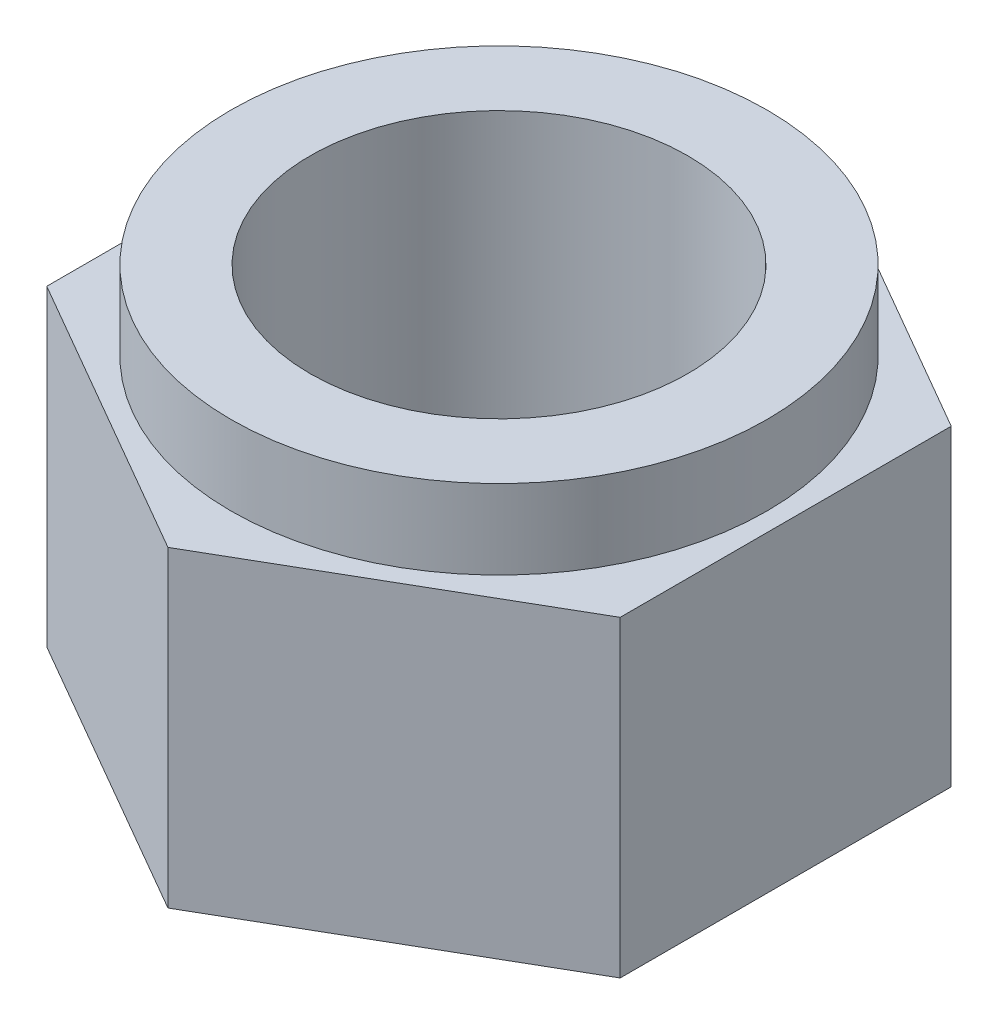
from build123d import *

# Parameters (mm, degrees)
SKETCH1_R           = 4.05
BOSS_EXTRUDE1_DEPTH = 6.7
SKETCH2_R           = 5.75
SKETCH2_R_2         = 4.05
BOSS_EXTRUDE2_DEPTH = 1.7


with BuildPart() as part:
    # Sketch1 → Boss-Extrude1 (new body)
    with BuildSketch(Plane(origin=(0, 0, 0), x_dir=(1, 0, 0), z_dir=(0, 1, 0))):
        Polygon((3.167381974, -0.528493855), (3.167381974, 6.572914456), (-2.982618026, 10.123618611), (-9.132618026, 6.572914456), (-9.132618026, -0.528493855), (-2.982618026, -4.079198011), align=None)
        with Locations((-2.982618026, 3.0222103)):
            Circle(SKETCH1_R, mode=Mode.SUBTRACT)
    extrude(amount=BOSS_EXTRUDE1_DEPTH)

    # Sketch2 → Boss-Extrude2 (add)
    with BuildSketch(Plane(origin=(0, 6.7, 0), x_dir=(1, 0, 0), z_dir=(0, 1, 0))):
        with Locations((-2.982618026, 3.0222103)):
            Circle(SKETCH2_R)
        with Locations((-2.982618026, 3.0222103)):
            Circle(SKETCH2_R_2, mode=Mode.SUBTRACT)
    extrude(amount=BOSS_EXTRUDE2_DEPTH)


solid = part.part
